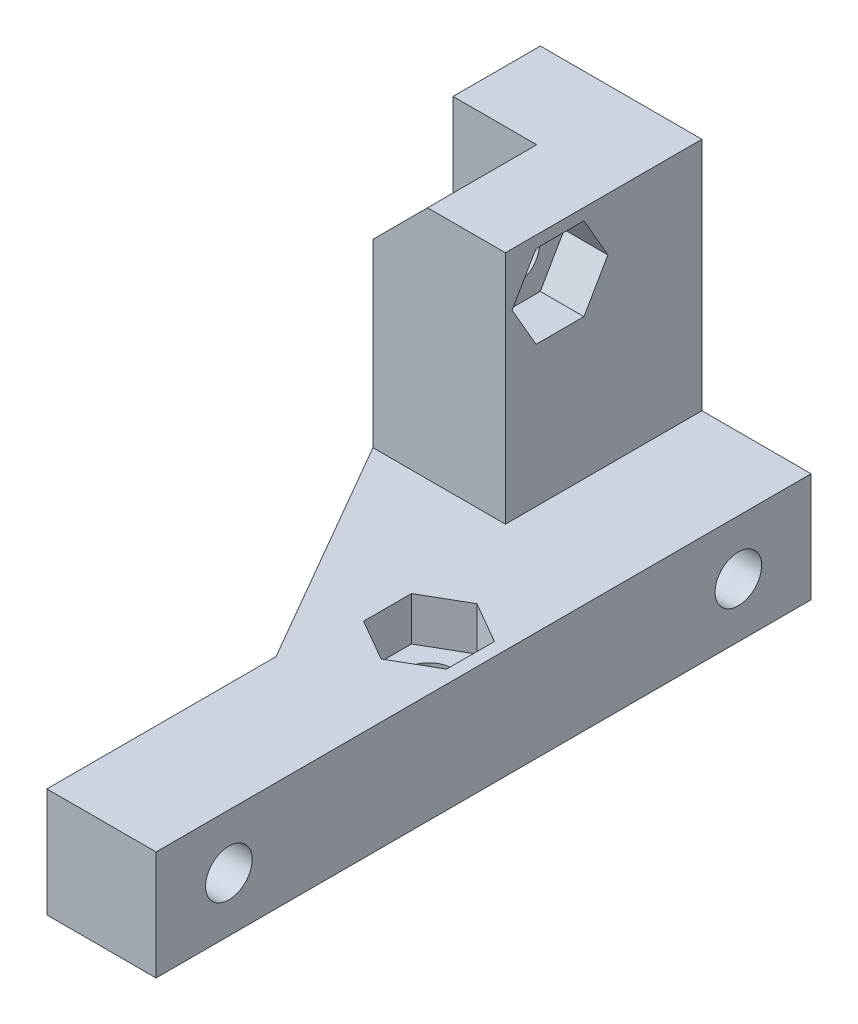
from build123d import *

# Parameters (mm, degrees)
SALIENTE_EXTRUIR1_DEPTH = 6
SALIENTE_EXTRUIR2_DEPTH = 7.5
SALIENTE_EXTRUIR3_DEPTH = 7.5
CROQUIS4_W              = 7.5
CROQUIS4_H              = 7.5
SALIENTE_EXTRUIR4_DEPTH = 31.5
CORTAR_EXTRUIR1_REACH   = 20.6
CROQUIS5_R              = 1.6
CORTAR_EXTRUIR2_DEPTH   = 14.1
CORTAR_EXTRUIR3_DEPTH   = 3
CORTAR_EXTRUIR4_REACH   = 25.65
CROQUIS8_R              = 1.6
CORTAR_EXTRUIR5_DEPTH   = 3
CORTAR_EXTRUIR6_REACH   = 13.1
CROQUIS10_R             = 1.6
CORTAR_EXTRUIR7_DEPTH   = 3


with BuildPart() as part:
    # Croquis1 → Saliente-Extruir1 (new body)
    with BuildSketch(Plane.XY):
        Polygon((0, 0), (16.6, 0), (16.6, 7.5), (9.1, 7.5), (9.1, 23.65), (3.75, 23.65), (-2, 23.65), (-2, 0), align=None)
    extrude(amount=SALIENTE_EXTRUIR1_DEPTH)

    # Croquis2 → Saliente-Extruir2 (add)
    with BuildSketch(Plane.XY.offset(6)):
        Polygon((0, 0), (0, 19.9), (3.75, 23.65), (9.1, 23.65), (9.1, 7.5), (16.6, 7.5), (16.6, 0), align=None)
    extrude(amount=SALIENTE_EXTRUIR2_DEPTH)

    # Croquis3 → Saliente-Extruir3 (add)
    with BuildSketch(Plane.XZ):
        Polygon((0, 13.5), (9.1, 29.261662349), (9.1, 13.5), align=None)
    extrude(amount=-SALIENTE_EXTRUIR3_DEPTH)

    # Croquis4 → Saliente-Extruir4 (add)
    with BuildSketch(Plane.XY.offset(13.5)):
        with Locations((12.85, 3.75)):
            Rectangle(CROQUIS4_W, CROQUIS4_H)
    extrude(amount=SALIENTE_EXTRUIR4_DEPTH)

    # Croquis5 → Cortar-Extruir1 (cut, up to next)
    with BuildSketch(Plane(origin=(16.6, 0, 0), x_dir=(0, 0, -1), z_dir=(1, 0, 0)), mode=Mode.PRIVATE) as cortar_extruir1_sk1:
        with Locations((-5, 3.75)):
            Circle(CROQUIS5_R)
    cortar_extruir1_tool1 = extrude(cortar_extruir1_sk1.sketch, amount=-CORTAR_EXTRUIR1_REACH, mode=Mode.PRIVATE) & part.part
    add(cortar_extruir1_tool1.solids().sort_by_distance((16.6, 3.75, 5))[0], mode=Mode.SUBTRACT)
    # Croquis5 → Cortar-Extruir1 (cut, up to next)
    with BuildSketch(Plane(origin=(16.6, 0, 0), x_dir=(0, 0, -1), z_dir=(1, 0, 0)), mode=Mode.PRIVATE) as cortar_extruir1_sk2:
        with Locations((-40, 3.75)):
            Circle(CROQUIS5_R)
    cortar_extruir1_tool2 = extrude(cortar_extruir1_sk2.sketch, amount=-CORTAR_EXTRUIR1_REACH, mode=Mode.PRIVATE) & part.part
    add(cortar_extruir1_tool2.solids().sort_by_distance((16.6, 3.75, 40))[0], mode=Mode.SUBTRACT)

    # Croquis6 → Cortar-Extruir2 (cut)
    with BuildSketch(Plane.ZY.offset(2)):
        Polygon((3.354551733, 0.9), (6.645448267, 0.9), (8.290896534, 3.75), (6.645448267, 6.6), (3.354551733, 6.6), (1.709103466, 3.75), align=None)
    extrude(amount=-CORTAR_EXTRUIR2_DEPTH, mode=Mode.SUBTRACT)

    # Croquis7 → Cortar-Extruir3 (cut)
    with BuildSketch(Plane.ZY.offset(-9.1)):
        Polygon((38.354551733, 0.9), (41.645448267, 0.9), (43.290896534, 3.75), (41.645448267, 6.6), (38.354551733, 6.6), (36.709103466, 3.75), align=None)
    extrude(amount=-CORTAR_EXTRUIR3_DEPTH, mode=Mode.SUBTRACT)

    # Croquis8 → Cortar-Extruir4 (cut, up to next)
    with BuildSketch(Plane.XZ, mode=Mode.PRIVATE) as cortar_extruir4_sk1:
        with Locations((12.85, 22.5)):
            Circle(CROQUIS8_R)
    cortar_extruir4_tool1 = extrude(cortar_extruir4_sk1.sketch, amount=-CORTAR_EXTRUIR4_REACH, mode=Mode.PRIVATE) & part.part
    add(cortar_extruir4_tool1.solids().sort_by_distance((12.85, 0, 22.5))[0], mode=Mode.SUBTRACT)

    # Croquis9 → Cortar-Extruir5 (cut)
    with BuildSketch(Plane(origin=(0, 7.5, 0), x_dir=(1, 0, 0), z_dir=(0, 1, 0))):
        Polygon((15.7, -20.854551733), (12.85, -19.209103466), (10, -20.854551733), (10, -24.145448267), (12.85, -25.790896534), (15.7, -24.145448267), align=None)
    extrude(amount=-CORTAR_EXTRUIR5_DEPTH, mode=Mode.SUBTRACT)

    # Croquis10 → Cortar-Extruir6 (cut, up to next)
    with BuildSketch(Plane(origin=(9.1, 0, 0), x_dir=(0, 0, -1), z_dir=(1, 0, 0)), mode=Mode.PRIVATE) as cortar_extruir6_sk1:
        with Locations((-9.75, 20)):
            Circle(CROQUIS10_R)
    cortar_extruir6_tool1 = extrude(cortar_extruir6_sk1.sketch, amount=-CORTAR_EXTRUIR6_REACH, mode=Mode.PRIVATE) & part.part
    add(cortar_extruir6_tool1.solids().sort_by_distance((9.1, 20, 9.75))[0], mode=Mode.SUBTRACT)

    # Croquis11 → Cortar-Extruir7 (cut)
    with BuildSketch(Plane(origin=(9.1, 0, 0), x_dir=(0, 0, -1), z_dir=(1, 0, 0))):
        Polygon((-8.104551733, 22.85), (-11.395448267, 22.85), (-13.040896534, 20), (-11.395448267, 17.15), (-8.104551733, 17.15), (-6.459103466, 20), align=None)
    extrude(amount=-CORTAR_EXTRUIR7_DEPTH, mode=Mode.SUBTRACT)


solid = part.part
